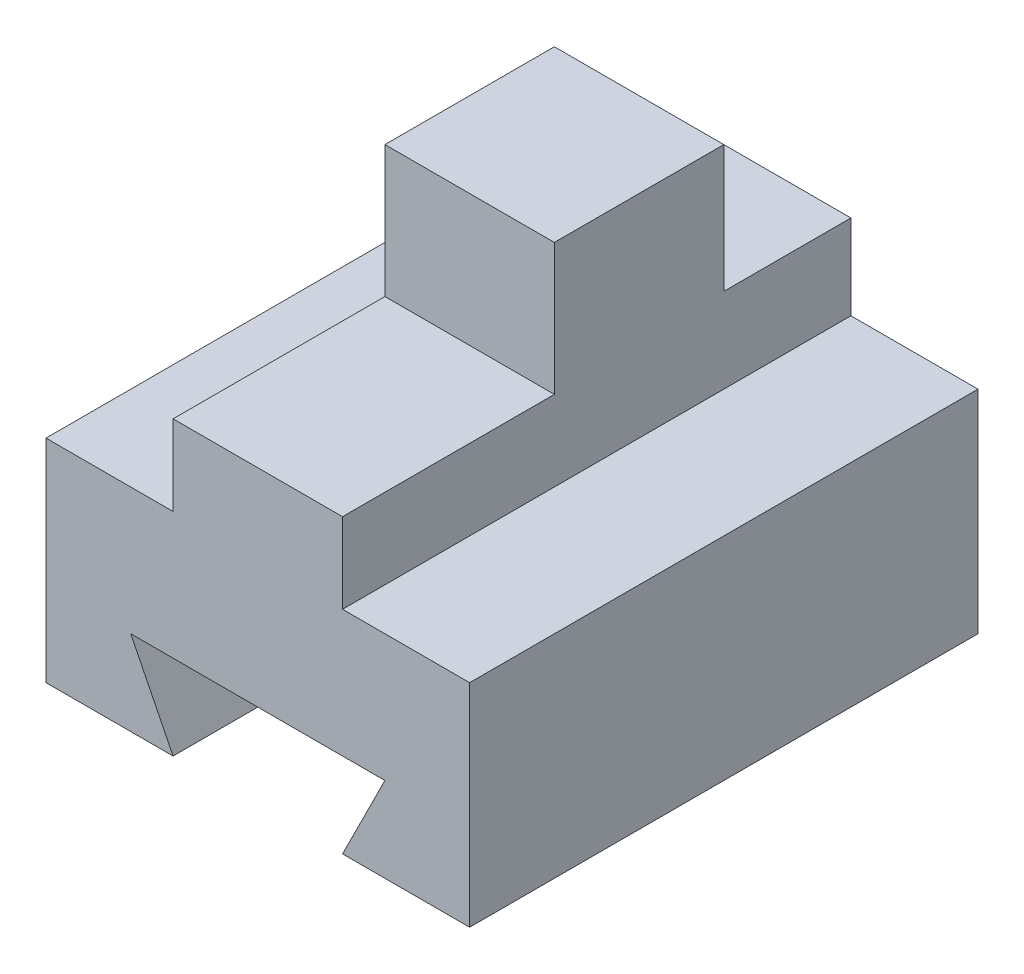
from build123d import *

# Parameters (mm, degrees)
IZIM1_W                     = 50
IZIM1_H                     = 50
Y_KSEKLIK_EKSTR_ZYON1_DEPTH = 60
KES_EKSTR_ZYON1_DEPTH       = 60
IZIM3_W                     = 15
IZIM3_H                     = 25
KES_EKSTR_ZYON2_DEPTH       = 60
IZIM4_W                     = 15
IZIM4_H                     = 15
IZIM4_W_2                   = 25
IZIM4_H_2                   = 15.532057861
KES_EKSTR_ZYON3_DEPTH       = 20


with BuildPart() as part:
    # Çizim1 → Yükseklik-Ekstrüzyon1 (new body)
    with BuildSketch(Plane.XY):
        with Locations((-13.102970675, -2.631578947)):
            Rectangle(IZIM1_W, IZIM1_H)
    extrude(amount=Y_KSEKLIK_EKSTR_ZYON1_DEPTH)

    # Çizim2 → Kes-Ekstrüzyon1 (cut)
    with BuildSketch(Plane.XY.offset(60)):
        Polygon((-28.102970675, -17.631578947), (1.897029325, -17.631578947), (-3.102970675, -27.631578947), (-23.102970675, -27.631578947), align=None)
    extrude(amount=-KES_EKSTR_ZYON1_DEPTH, mode=Mode.SUBTRACT)

    # Çizim3 → Kes-Ekstrüzyon2 (cut)
    with BuildSketch(Plane.XY.offset(60)):
        with Locations((4.397029325, 9.868421053)):
            Rectangle(IZIM3_W, IZIM3_H)
        with Locations((-30.602970675, 9.868421053)):
            Rectangle(IZIM3_W, IZIM3_H)
    extrude(amount=-KES_EKSTR_ZYON2_DEPTH, mode=Mode.SUBTRACT)

    # Çizim4 → Kes-Ekstrüzyon3 (cut)
    with BuildSketch(Plane.ZY.offset(23.102970675)):
        with Locations((7.5, 14.868421053)):
            Rectangle(IZIM4_W, IZIM4_H)
        with Locations((47.5, 14.602392123)):
            Rectangle(IZIM4_W_2, IZIM4_H_2)
    extrude(amount=-KES_EKSTR_ZYON3_DEPTH, mode=Mode.SUBTRACT)


solid = part.part
